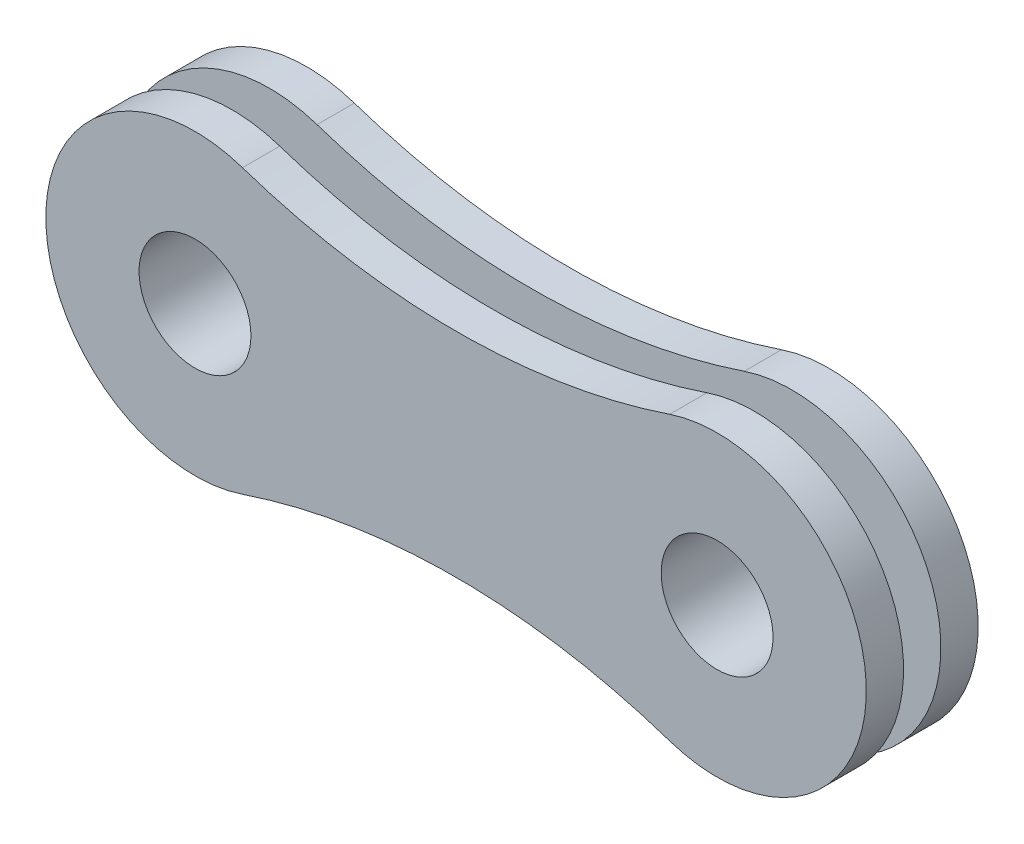
from build123d import *

# Parameters (mm, degrees)
SKETCH1_R           = 1.5
BOSS_EXTRUDE1_DEPTH = 1
SKETCH2_R           = 2
SKETCH2_R_2         = 1.5
BOSS_EXTRUDE2_DEPTH = 2


with BuildPart() as part:
    # Sketch1 → Boss-Extrude1 (new body)
    with BuildSketch(Plane.XY):
        with BuildLine():
            ThreePointArc((-5.727272727, 3.792118839), (-11, 0), (-5.727272727, -3.792118839))
            ThreePointArc((-5.727272727, -3.792118839), (0, -2.856653615), (5.727272727, -3.792118839))
            ThreePointArc((5.727272727, -3.792118839), (11, 0), (5.727272727, 3.792118839))
            ThreePointArc((5.727272727, 3.792118839), (0, 2.856653615), (-5.727272727, 3.792118839))
        make_face()
        with Locations((-7, 0)):
            Circle(SKETCH1_R, mode=Mode.SUBTRACT)
        with Locations((7, 0)):
            Circle(SKETCH1_R, mode=Mode.SUBTRACT)
    boss_extrude1 = extrude(amount=BOSS_EXTRUDE1_DEPTH)

    # Sketch2 → Boss-Extrude2 (add)
    with BuildSketch(Plane.XY.offset(1)):
        with Locations((-7, 0)):
            Circle(SKETCH2_R)
        with Locations((-7, 0)):
            Circle(SKETCH2_R_2, mode=Mode.SUBTRACT)
        with Locations((7, 0)):
            Circle(SKETCH2_R)
        with Locations((7, 0)):
            Circle(SKETCH2_R_2, mode=Mode.SUBTRACT)
    extrude(amount=BOSS_EXTRUDE2_DEPTH)

    # Mirror1: Boss-Extrude1 across plane
    add(boss_extrude1.mirror(Plane.XY.offset(1.5)))


solid = part.part
